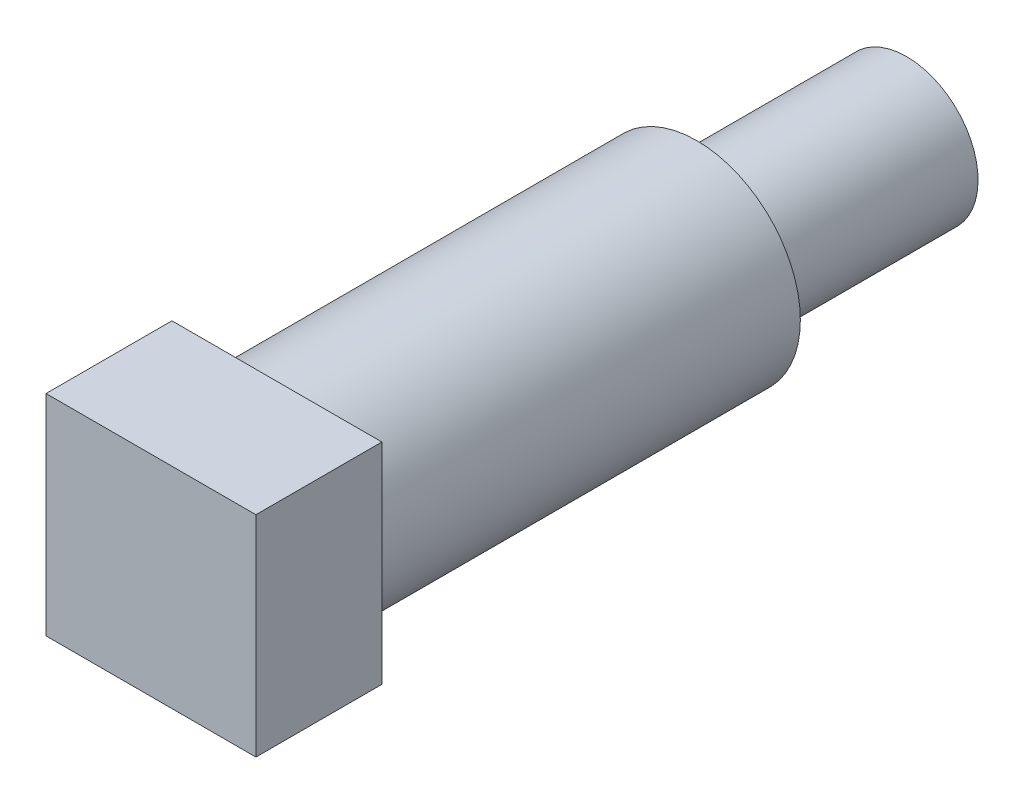
from build123d import *

# Parameters (mm, degrees)
SKETCH6_R           = 3.687499751
CUT_EXTRUDE3_DEPTH  = 29.1338
SKETCH7_R           = 3.133725
BOSS_EXTRUDE1_DEPTH = 3.81
SKETCH8_R           = 2.159
BOSS_EXTRUDE2_DEPTH = 6.35
SKETCH9_R           = 4.699
CUT_EXTRUDE4_DEPTH  = 6.35
SKETCH10_W          = 6.35
SKETCH10_H          = 6.35
BOSS_EXTRUDE3_DEPTH = 3.81


with BuildPart() as part:
    # Sketch1 → Revolve1 (revolve)
    with BuildSketch(Plane(origin=(0, 0, 0), x_dir=(0, 0, -1), z_dir=(1, 0, 0))):
        Polygon((4.892085627, 0), (44.3738, 0), (44.3738, 2.159), (43.409235, 3.123565), (25.3238, 3.123565), (18.9738, 3.133725), (6.4516, 3.133725), (6.2738, 3.133725), (6.2738, 3.311525), (6.2738, 4.445), (6.2738, 4.699), (6.0198, 4.699), (0.635, 4.699), (0, 4.699), (0, 4.064), (0, 3.19405), (0, 0), align=None)
    revolve(axis=Axis((0, 0, -4.892085627), (0, 0, -1)))

    # Sketch6 → Cut-Extrude3 (cut)
    with BuildSketch(Plane(origin=(0, 0, -44.3738), x_dir=(-1, 0, 0), z_dir=(0, 0, -1))):
        Circle(SKETCH6_R)
    extrude(amount=-CUT_EXTRUDE3_DEPTH, mode=Mode.SUBTRACT)

    # Sketch7 → Boss-Extrude1 (add)
    with BuildSketch(Plane(origin=(0, 0, -15.24), x_dir=(-1, 0, 0), z_dir=(0, 0, -1))):
        Circle(SKETCH7_R)
    extrude(amount=BOSS_EXTRUDE1_DEPTH)

    # Sketch8 → Boss-Extrude2 (add)
    with BuildSketch(Plane(origin=(0, 0, -19.05), x_dir=(-1, 0, 0), z_dir=(0, 0, -1))):
        Circle(SKETCH8_R)
    extrude(amount=BOSS_EXTRUDE2_DEPTH)

    # Sketch9 → Cut-Extrude4 (cut)
    with BuildSketch(Plane.XY):
        Circle(SKETCH9_R)
    extrude(amount=-CUT_EXTRUDE4_DEPTH, mode=Mode.SUBTRACT)

    # Sketch10 → Boss-Extrude3 (add)
    with BuildSketch(Plane.XY.offset(-6.35)):
        Rectangle(SKETCH10_W, SKETCH10_H)
    extrude(amount=BOSS_EXTRUDE3_DEPTH)


solid = part.part
